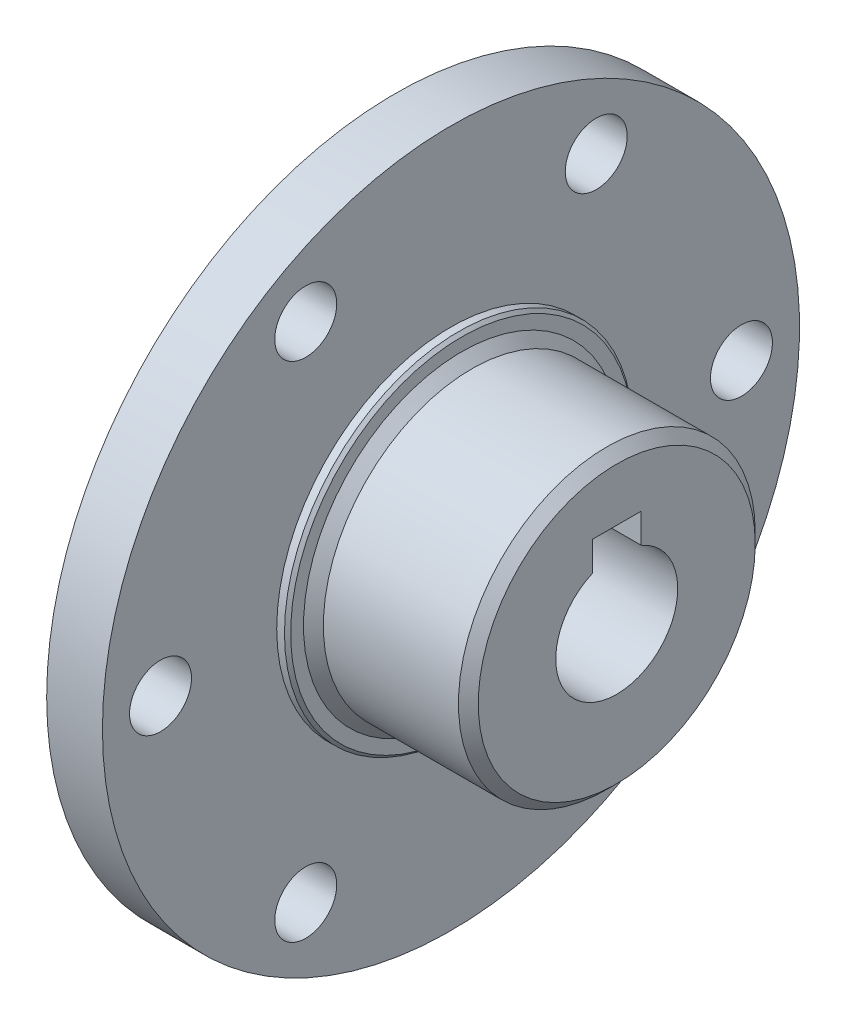
from build123d import *

# Parameters (mm, degrees)
SKETCH1_W                  = 4.572
SKETCH1_H                  = 28.575
SKETCH2_R                  = 14.2875
BOSS_EXTRUDE1_DEPTH        = 0.889
SKETCH3_R                  = 12.1666
BOSS_EXTRUDE2_DEPTH        = 12.7
SKETCH4_R                  = 14.2875
BOSS_EXTRUDE3_DEPTH        = 0.889
CUT_EXTRUDE1_DEPTH         = 20.05
SKETCH6_W                  = 19.05
SKETCH6_H                  = 5
F_10_CLEARANCE_HOLE1_D     = 5.08
F_10_CLEARANCE_HOLE1_DEPTH = 18.161
CHAMFER1_SIZE              = 0.254
CHAMFER2_SIZE              = 0.8128


with BuildPart() as part:
    # Sketch1 → Revolve1 (revolve)
    with BuildSketch(Plane(origin=(0, 0, 0), x_dir=(-1, 0, 0), z_dir=(0, 0, -1))):
        with Locations((15.321066246, 14.2875)):
            Rectangle(SKETCH1_W, SKETCH1_H)
    revolve(axis=Axis((-13.035066246, 0, 0), (-1, 0, 0)))

    # Sketch2 → Boss-Extrude1 (add)
    with BuildSketch(Plane(origin=(-13.035066246, 0, 0), x_dir=(0, 0, -1), z_dir=(1, 0, 0))):
        Circle(SKETCH2_R)
    extrude(amount=BOSS_EXTRUDE1_DEPTH)

    # Sketch3 → Boss-Extrude2 (add)
    with BuildSketch(Plane(origin=(-12.146066246, 0, 0), x_dir=(0, 0, -1), z_dir=(1, 0, 0))):
        Circle(SKETCH3_R)
    extrude(amount=BOSS_EXTRUDE2_DEPTH)

    # Sketch4 → Boss-Extrude3 (add)
    with BuildSketch(Plane.ZY.offset(17.607066246)):
        Circle(SKETCH4_R)
    extrude(amount=BOSS_EXTRUDE3_DEPTH)

    # Sketch5 → Cut-Extrude1 (cut, through all)
    with BuildSketch(Plane.ZY.offset(18.496066246)):
        with BuildLine():
            Line((2, 4.582575695), (2, 7))
            Line((2, 7), (-2, 7))
            Line((-2, 7), (-2, 4.582575695))
            ThreePointArc((-2, 4.582575695), (0, 5), (2, 4.582575695))
        make_face()
    extrude(amount=-CUT_EXTRUDE1_DEPTH, mode=Mode.SUBTRACT)

    # Sketch6 → Cut-Revolve1 (revolve, cut)
    with BuildSketch(Plane(origin=(0, 0, 0), x_dir=(-1, 0, 0), z_dir=(0, 0, -1))):
        with Locations((8.971066246, 2.5)):
            Rectangle(SKETCH6_W, SKETCH6_H)
    revolve(axis=Axis((0.553933754, 0, 0), (-1, 0, 0)), mode=Mode.SUBTRACT)

    # #10 Clearance Hole1
    with Locations(Plane.ZY.offset(17.607066246)):
        with Locations((11.90625, 20.622229928), (-11.90625, 20.622229928), (-23.8125, 0), (-11.90625, -20.622229928), (11.90625, -20.622229928), (23.8125, 0)):
            Hole(F_10_CLEARANCE_HOLE1_D / 2, depth=F_10_CLEARANCE_HOLE1_DEPTH)

    # Chamfer1
    chamfer1_edges = [part.edges().sort_by_distance(p)[0] for p in [
        (-18.496066246, 0, -14.2875),
        (-12.146066246, 0, 14.2875),
    ]]
    chamfer(chamfer1_edges, length=CHAMFER1_SIZE)

    # Chamfer2
    chamfer2_edges = [part.edges().sort_by_distance(p)[0] for p in [
        (-12.146066246, 0, 12.1666),
        (0.553933754, 0, 12.1666),
    ]]
    chamfer(chamfer2_edges, length=CHAMFER2_SIZE)


solid = part.part
